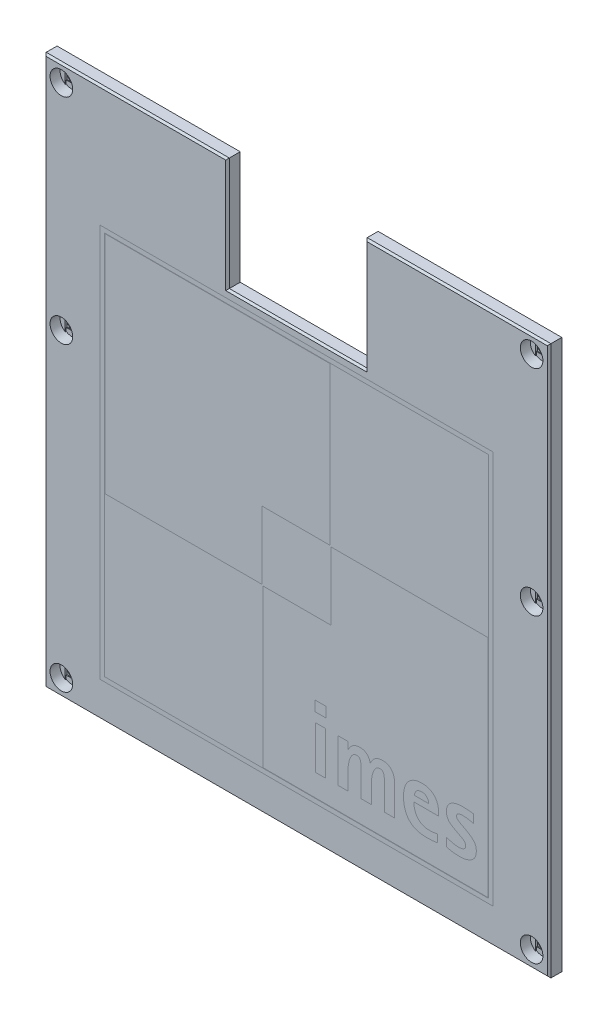
from build123d import *

# Parameters (mm, degrees)
SKETCH1_R             = 1.35
BOSS_EXTRUDE1_DEPTH   = 2.8
SKETCH3_R             = 2.5
CUT_EXTRUDE1_DEPTH    = 2.2
SKETCH4_W             = 91.5
SKETCH4_H             = 85.5
CUT_EXTRUDE2_DEPTH    = 1.5
CUT_EXTRUDE3_DEPTH    = 0.2
SKETCH6_W             = 2.7
SKETCH6_H             = 2.7
CUT_EXTRUDE4_DEPTH    = 0.2
CHAMFER1_SIZE         = 0.4
CUT_EXTRUDE5_DEPTH    = 1
BOSS_EXTRUDE2_DEPTH   = 1
BOSS_EXTRUDE2_2_DEPTH = 1
SKETCH10_W            = 87
SKETCH10_H            = 87
SKETCH10_W_2          = 85
SKETCH10_H_2          = 85
CUT_EXTRUDE6_DEPTH    = 1
SKETCH10_2_W          = 87
SKETCH10_2_H          = 87
SKETCH10_2_W_2        = 85
SKETCH10_2_H_2        = 85
BOSS_EXTRUDE3_DEPTH   = 1
SKETCH11_W            = 2.420833333
SKETCH11_H            = 2.24
SKETCH11_W_2          = 2.237083334
SKETCH11_H_2          = 9.52
CUT_EXTRUDE7_DEPTH    = 1
SKETCH11_2_W          = 2.420833333
SKETCH11_2_H          = 2.24
BOSS_EXTRUDE4_DEPTH   = 1
SKETCH11_2_W_2        = 2.237083334
SKETCH11_2_H_2        = 9.52
BOSS_EXTRUDE4_2_DEPTH = 1
BOSS_EXTRUDE4_3_DEPTH = 1
BOSS_EXTRUDE4_4_DEPTH = 1
BOSS_EXTRUDE4_5_DEPTH = 1


with BuildPart() as part:
    # Sketch1 → Boss-Extrude1 (new body)
    with BuildSketch(Plane.XY):
        Polygon((-15.25, 53.75), (-15.25, 28.75), (15.25, 28.75), (15.25, 53.75), (55.875, 53.75), (55.875, -67.75), (-55.75, -67.75), (-55.75, 53.75), align=None)
        with Locations((-52, 50)):
            Circle(SKETCH1_R, mode=Mode.SUBTRACT)
        with Locations((-52, 2.6)):
            Circle(SKETCH1_R, mode=Mode.SUBTRACT)
        with Locations((-52, -64)):
            Circle(SKETCH1_R, mode=Mode.SUBTRACT)
        with Locations((52, 50)):
            Circle(SKETCH1_R, mode=Mode.SUBTRACT)
        with Locations((52, 2.6)):
            Circle(SKETCH1_R, mode=Mode.SUBTRACT)
        with Locations((52, -64)):
            Circle(SKETCH1_R, mode=Mode.SUBTRACT)
    extrude(amount=BOSS_EXTRUDE1_DEPTH)

    # Sketch3 → Cut-Extrude1 (cut)
    with BuildSketch(Plane.XY.offset(2.8)):
        with Locations((-52, 50)):
            Circle(SKETCH3_R)
        with Locations((-52, 2.6)):
            Circle(SKETCH3_R)
        with Locations((-52, -64)):
            Circle(SKETCH3_R)
        with Locations((52, -64)):
            Circle(SKETCH3_R)
        with Locations((52, 2.6)):
            Circle(SKETCH3_R)
        with Locations((52, 50)):
            Circle(SKETCH3_R)
    extrude(amount=-CUT_EXTRUDE1_DEPTH, mode=Mode.SUBTRACT)

    # Sketch4 → Cut-Extrude2 (cut)
    with BuildSketch(Plane(origin=(0, 0, 0), x_dir=(-1, 0, 0), z_dir=(0, 0, -1))):
        with Locations((0, -15)):
            Rectangle(SKETCH4_W, SKETCH4_H)
    extrude(amount=-CUT_EXTRUDE2_DEPTH, mode=Mode.SUBTRACT)

    # Sketch5 → Cut-Extrude3 (cut)
    with BuildSketch(Plane.XY.offset(0.6)):
        with BuildLine():
            Line((-53.35, 47.895837459), (-53.35, 52.104162541))
            ThreePointArc((-53.35, 52.104162541), (-52, 52.5), (-50.65, 52.104162541))
            Line((-50.65, 52.104162541), (-50.65, 47.895837459))
            ThreePointArc((-50.65, 47.895837459), (-52, 47.5), (-53.35, 47.895837459))
        make_face()
        with BuildLine():
            Line((-53.35, 0.495837459), (-53.35, 4.704162541))
            ThreePointArc((-53.35, 4.704162541), (-52, 5.1), (-50.65, 4.704162541))
            Line((-50.65, 4.704162541), (-50.65, 0.495837459))
            ThreePointArc((-50.65, 0.495837459), (-52, 0.1), (-53.35, 0.495837459))
        make_face()
        with BuildLine():
            Line((-53.35, -66.104162541), (-53.35, -61.895837459))
            ThreePointArc((-53.35, -61.895837459), (-52, -61.5), (-50.65, -61.895837459))
            Line((-50.65, -61.895837459), (-50.65, -66.104162541))
            ThreePointArc((-50.65, -66.104162541), (-52, -66.5), (-53.35, -66.104162541))
        make_face()
    cut_extrude3 = extrude(amount=-CUT_EXTRUDE3_DEPTH, mode=Mode.SUBTRACT)

    # Sketch6 → Cut-Extrude4 (cut)
    with BuildSketch(Plane.XY.offset(0.4)):
        with Locations((-52, -64)):
            Rectangle(SKETCH6_W, SKETCH6_H)
        with Locations((-52, 2.6)):
            Rectangle(SKETCH6_W, SKETCH6_H)
        with Locations((-52, 50)):
            Rectangle(SKETCH6_W, SKETCH6_H)
    cut_extrude4 = extrude(amount=-CUT_EXTRUDE4_DEPTH, mode=Mode.SUBTRACT)

    # Mirror1: Cut-Extrude3, Cut-Extrude4 across plane
    add(cut_extrude3.mirror(Plane(origin=(0, 0, 0), x_dir=(0, 0, 1), z_dir=(1, 0, 0))), mode=Mode.SUBTRACT)
    add(cut_extrude4.mirror(Plane(origin=(0, 0, 0), x_dir=(0, 0, 1), z_dir=(1, 0, 0))), mode=Mode.SUBTRACT)

    # Chamfer1
    chamfer1_edges = [part.edges().sort_by_distance(p)[0] for p in [
        (55.875, -7, 2.8),
        (35.5625, 53.75, 2.8),
        (15.25, 41.25, 2.8),
        (0, 28.75, 2.8),
        (-15.25, 41.25, 2.8),
        (-35.5, 53.75, 2.8),
        (-55.75, -7, 2.8),
        (0.0625, -67.75, 2.8),
    ]]
    chamfer(chamfer1_edges, length=CHAMFER1_SIZE)

    # Sketch8 → Cut-Extrude5 (cut)
    with BuildSketch(Plane.XY.offset(2.8)):
        Polygon((7.4, -8.9), (7.4, 25.9), (-42.4, 25.9), (-42.4, -23.9), (-7.6, -23.9), (-7.6, -8.9), align=None)
        Polygon((7.6, -9.1), (42.4, -9.1), (42.4, -58.9), (-7.4, -58.9), (-7.4, -24.1), (7.6, -24.1), align=None)
    extrude(amount=-CUT_EXTRUDE5_DEPTH, mode=Mode.SUBTRACT)

    # Sketch10 → Cut-Extrude6 (cut)
    with BuildSketch(Plane.XY.offset(2.8)):
        with Locations((0, -16.5)):
            Rectangle(SKETCH10_W, SKETCH10_H)
        with Locations((0, -16.5)):
            Rectangle(SKETCH10_W_2, SKETCH10_H_2, mode=Mode.SUBTRACT)
    extrude(amount=-CUT_EXTRUDE6_DEPTH, mode=Mode.SUBTRACT)


with BuildPart() as body_2:
    # Sketch9 → Boss-Extrude2 (new body)
    with BuildSketch(Plane.XY.offset(1.8)):
        Polygon((42.4, -58.9), (42.4, -9.1), (7.6, -9.1), (7.6, -24.1), (-7.4, -24.1), (-7.4, -58.9), align=None)
    extrude(amount=BOSS_EXTRUDE2_DEPTH)

    # Sketch11 → Cut-Extrude7 (cut)
    with BuildSketch(Plane.XY.offset(2.8)):
        with Locations((5.301989939, -41.306666667)):
            Rectangle(SKETCH11_W, SKETCH11_H)
        with Locations((5.312198272, -49.24)):
            Rectangle(SKETCH11_W_2, SKETCH11_H_2)
        with BuildLine():
            Line((16.551573272, -54), (14.314489939, -54))
            Line((14.314489939, -54), (14.314489939, -48.668333333))
            add(Edge.make_bspline(
                [(14.314489939, -48.668333333), (14.313686685, -48.482571253), (14.312175479, -48.133086674), (14.278360319, -47.640712175), (14.232210349, -47.211572426), (14.172597166, -46.893633433), (14.107175652, -46.674232022), (14.042196618, -46.535243015), (13.957841011, -46.418719337), (13.856161095, -46.322230666), (13.736942045, -46.248548263), (13.601692447, -46.195614954), (13.448414032, -46.167272457), (13.34140672, -46.162513003), (13.284906605, -46.16)],
                knots=[0, 0, 0, 0, 0.000557152, 0.001048201, 0.001479809, 0.001851612, 0.002016733, 0.002165454, 0.002309556, 0.002445737, 0.002583316, 0.002727389, 0.002878971, 0.00304854, 0.00304854, 0.00304854, 0.00304854], degree=3))
            add(Edge.make_bspline(
                [(13.284906605, -46.16), (13.23232302, -46.162736834), (13.129269761, -46.168100479), (12.976620173, -46.195969001), (12.834650775, -46.25367671), (12.65031574, -46.353254313), (12.435900889, -46.529460995), (12.213950311, -46.801404357), (12.017705386, -47.124509235), (11.844159352, -47.488037139), (11.697897987, -47.886450243), (11.628537057, -48.166876883), (11.593239939, -48.309583333)],
                knots=[0, 0, 0, 0, 0.000157932, 0.000309514, 0.000462799, 0.000615499, 0.000937088, 0.001287003, 0.00166419, 0.002068598, 0.002493961, 0.002934726, 0.002934726, 0.002934726, 0.002934726], degree=3))
            add(Edge.make_bspline(
                [(11.593239939, -48.309583333), (11.562337157, -48.458025184), (11.499815905, -48.758346705), (11.437775373, -49.216251476), (11.39825174, -49.677767314), (11.394066278, -49.985615063), (11.391989939, -50.138333333)],
                knots=[0, 0, 0, 0, 0.000454748, 0.000920027, 0.001385324, 0.001843389, 0.001843389, 0.001843389, 0.001843389], degree=3))
            Line((11.391989939, -50.138333333), (11.391989939, -54))
            Line((11.391989939, -54), (9.151989939, -54))
            Line((9.151989939, -54), (9.151989939, -44.48))
            Line((9.151989939, -44.48), (11.371573272, -44.48))
            Line((11.371573272, -44.48), (11.371573272, -46.09875))
            Line((11.371573272, -46.09875), (11.409489939, -46.09875))
            add(Edge.make_bspline(
                [(11.409489939, -46.09875), (11.473376644, -45.963842947), (11.59767667, -45.70136345), (11.834161815, -45.343504102), (12.106671485, -45.033324948), (12.412237587, -44.764956333), (12.76140059, -44.551444881), (13.154373097, -44.399999465), (13.589804927, -44.3075479), (13.894010556, -44.298192012), (14.051989939, -44.293333333)],
                knots=[0, 0, 0, 0, 0.000447402, 0.000870479, 0.001281771, 0.001682916, 0.002086092, 0.002502603, 0.002940783, 0.003414183, 0.003414183, 0.003414183, 0.003414183], degree=3))
            add(Edge.make_bspline(
                [(14.051989939, -44.293333333), (14.196386101, -44.29832864), (14.473501185, -44.307915285), (14.866870226, -44.397474346), (15.21860961, -44.540852097), (15.527812089, -44.744235726), (15.788505717, -45.01175304), (16.006545498, -45.334125761), (16.175536509, -45.716406069), (16.250138065, -45.994462985), (16.289073272, -46.139583333)],
                knots=[0, 0, 0, 0, 0.000432651, 0.000830314, 0.001202974, 0.001566997, 0.001932047, 0.002316306, 0.002728836, 0.003179176, 0.003179176, 0.003179176, 0.003179176], degree=3))
            Line((16.289073272, -46.139583333), (16.329906605, -46.139583333))
            add(Edge.make_bspline(
                [(16.329906605, -46.139583333), (16.404348942, -45.987351559), (16.547523057, -45.694565886), (16.8236893, -45.311447986), (17.121737493, -44.984613501), (17.459823406, -44.729169162), (17.823197859, -44.532075393), (18.212208596, -44.394825734), (18.623245144, -44.30604211), (18.906798996, -44.297620689), (19.051156605, -44.293333333)],
                knots=[0, 0, 0, 0, 0.000507508, 0.000976085, 0.00141149, 0.001829755, 0.002240839, 0.002646769, 0.003063771, 0.003496235, 0.003496235, 0.003496235, 0.003496235], degree=3))
            add(Edge.make_bspline(
                [(19.051156605, -44.293333333), (19.162128041, -44.296011447), (19.377211358, -44.301202132), (19.688626773, -44.344652447), (19.976385472, -44.420507531), (20.241337234, -44.526459651), (20.482962243, -44.658263208), (20.705873265, -44.810645716), (20.903417048, -44.990290645), (21.082778761, -45.188600097), (21.237433908, -45.408549884), (21.369170289, -45.647567577), (21.481323721, -45.903631134), (21.563276586, -46.180808014), (21.631177774, -46.470870114), (21.676327358, -46.776265483), (21.707264981, -47.094636368), (21.709841789, -47.312004545), (21.711156605, -47.422916667)],
                knots=[0, 0, 0, 0, 0.00033282, 0.000645066, 0.000940788, 0.001223509, 0.001498884, 0.001765068, 0.002031509, 0.002297949, 0.002565806, 0.002836067, 0.003115641, 0.003402559, 0.00370184, 0.004008743, 0.004327994, 0.004660609, 0.004660609, 0.004660609, 0.004660609], degree=3))
            Line((21.711156605, -47.422916667), (21.711156605, -54))
            Line((21.711156605, -54), (19.474073272, -54))
            Line((19.474073272, -54), (19.474073272, -48.528333333))
            add(Edge.make_bspline(
                [(19.474073272, -48.528333333), (19.473221838, -48.352300679), (19.471620776, -48.021283271), (19.438440361, -47.554996781), (19.390322126, -47.149732416), (19.336041322, -46.849239036), (19.269011046, -46.642620111), (19.202165981, -46.512626337), (19.11640835, -46.403519726), (19.013809355, -46.311632834), (18.890844571, -46.243276631), (18.751058454, -46.192975161), (18.594449059, -46.163785788), (18.484477246, -46.161299629), (18.426989939, -46.16)],
                knots=[0, 0, 0, 0, 0.000527989, 0.000992848, 0.001401285, 0.001752498, 0.00190653, 0.002051339, 0.002188454, 0.002320704, 0.002461794, 0.002607569, 0.00276488, 0.002937185, 0.002937185, 0.002937185, 0.002937185], degree=3))
            add(Edge.make_bspline(
                [(18.426989939, -46.16), (18.331576773, -46.166361664), (18.142443407, -46.178972115), (17.874558895, -46.293299659), (17.628727852, -46.470616752), (17.415067159, -46.718757608), (17.227199685, -47.014314201), (17.052738095, -47.341616073), (16.908240641, -47.704310355), (16.832471045, -47.959901718), (16.793656605, -48.090833333)],
                knots=[0, 0, 0, 0, 0.000285073, 0.000565089, 0.00085973, 0.001188175, 0.001540078, 0.001909299, 0.00229926, 0.002708842, 0.002708842, 0.002708842, 0.002708842], degree=3))
            add(Edge.make_bspline(
                [(16.793656605, -48.090833333), (16.755177885, -48.253678629), (16.67668304, -48.585875653), (16.60531819, -49.097325017), (16.560133047, -49.617366396), (16.554418238, -49.965182409), (16.551573272, -50.138333333)],
                knots=[0, 0, 0, 0, 0.000501743, 0.001023533, 0.001547446, 0.002066818, 0.002066818, 0.002066818, 0.002066818], degree=3))
            Line((16.551573272, -50.138333333), (16.551573272, -54))
        make_face()
        with BuildLine():
            add(Edge.make_bspline(
                [(31.146573272, -54), (30.948633988, -54.034140742), (30.544754004, -54.103802319), (29.925184631, -54.152030212), (29.296764308, -54.182125246), (28.876476435, -54.185158027), (28.667406605, -54.186666667)],
                knots=[0, 0, 0, 0, 0.000602276, 0.001228898, 0.001862486, 0.00248963, 0.00248963, 0.00248963, 0.00248963], degree=3))
            add(Edge.make_bspline(
                [(28.667406605, -54.186666667), (28.456245849, -54.182438475), (28.048238171, -54.174268705), (27.458086548, -54.104586272), (26.914315853, -53.985052647), (26.413389292, -53.823111993), (25.958466237, -53.61096192), (25.545424205, -53.35983915), (25.172490736, -53.06978598), (24.848075621, -52.733605079), (24.56359642, -52.361388441), (24.321808959, -51.952971154), (24.115558498, -51.511786768), (23.950937542, -51.035321785), (23.823165687, -50.527705633), (23.734384439, -49.991101409), (23.676835479, -49.426953028), (23.671148832, -49.040841259), (23.668239939, -48.843333333)],
                knots=[0, 0, 0, 0, 0.000633347, 0.001223761, 0.001779285, 0.002301327, 0.002799804, 0.003281513, 0.003748881, 0.004212962, 0.004679063, 0.005151257, 0.005634051, 0.006137698, 0.006661172, 0.007202526, 0.007768164, 0.008360506, 0.008360506, 0.008360506, 0.008360506], degree=3))
            add(Edge.make_bspline(
                [(23.668239939, -48.843333333), (23.670679906, -48.683765408), (23.675481498, -48.369752948), (23.724138608, -47.907889675), (23.799476888, -47.463493977), (23.902825551, -47.037454676), (24.040180862, -46.634305104), (24.20702458, -46.255897891), (24.41514747, -45.910733069), (24.646761925, -45.589161825), (24.918900043, -45.302050501), (25.222341231, -45.04312192), (25.564128522, -44.822262536), (25.93686423, -44.629930644), (26.346875594, -44.477947118), (26.793581426, -44.372469228), (27.274912743, -44.302241295), (27.608390334, -44.296368527), (27.780739939, -44.293333333)],
                knots=[0, 0, 0, 0, 0.000478556, 0.000941746, 0.001391518, 0.001830106, 0.002255309, 0.00266784, 0.003068008, 0.003462363, 0.003854413, 0.004251765, 0.004656247, 0.00507236, 0.005507951, 0.00596423, 0.006447244, 0.006963898, 0.006963898, 0.006963898, 0.006963898], degree=3))
            add(Edge.make_bspline(
                [(27.780739939, -44.293333333), (27.927749627, -44.296168181), (28.213164749, -44.301671958), (28.627108854, -44.359295882), (29.013618747, -44.44785181), (29.371982236, -44.574644967), (29.702759219, -44.731671309), (30.004706565, -44.920287518), (30.280746502, -45.132921366), (30.527025179, -45.374775719), (30.746906172, -45.639519393), (30.934207828, -45.932557372), (31.095285588, -46.246455255), (31.222178659, -46.58497307), (31.325446112, -46.941604739), (31.396722231, -47.317584093), (31.442140258, -47.711524243), (31.447279013, -47.979870318), (31.449906605, -48.117083333)],
                knots=[0, 0, 0, 0, 0.000440764, 0.000855731, 0.001251206, 0.001628494, 0.001993777, 0.002347464, 0.002694597, 0.003036979, 0.003380923, 0.003724756, 0.004078251, 0.00443738, 0.004807567, 0.005190817, 0.005584092, 0.0059956, 0.0059956, 0.0059956, 0.0059956], degree=3))
            Line((31.449906605, -48.117083333), (31.449906605, -48.773333333))
            Line((31.449906605, -48.773333333), (25.986989939, -48.773333333))
            Line((25.986989939, -48.773333333), (25.986989939, -49.00375))
            add(Edge.make_bspline(
                [(25.986989939, -49.00375), (25.990016312, -49.120522993), (25.996011873, -49.351862431), (26.037122844, -49.694604786), (26.10804176, -50.027889506), (26.203223457, -50.351297159), (26.32573212, -50.659481766), (26.470807623, -50.950931588), (26.645687078, -51.218813195), (26.836439446, -51.472399643), (27.057367822, -51.700666376), (27.302957561, -51.906237625), (27.575802393, -52.083962617), (27.87159575, -52.235978332), (28.190130956, -52.361024318), (28.533023193, -52.441995963), (28.895035571, -52.497756307), (29.14356878, -52.503644093), (29.271156605, -52.506666667)],
                knots=[0, 0, 0, 0, 0.000350304, 0.000693988, 0.001033777, 0.001371531, 0.001704082, 0.002027569, 0.002346341, 0.002662527, 0.002978134, 0.003297053, 0.003621446, 0.00395278, 0.004293481, 0.004645057, 0.005007628, 0.005390112, 0.005390112, 0.005390112, 0.005390112], degree=3))
            add(Edge.make_bspline(
                [(29.271156605, -52.506666667), (29.420928332, -52.50410257), (29.723712122, -52.498918903), (30.185228493, -52.466193349), (30.661376762, -52.408280475), (30.982529838, -52.349847355), (31.146573272, -52.32)],
                knots=[0, 0, 0, 0, 0.000449318, 0.000908357, 0.001387339, 0.001887461, 0.001887461, 0.001887461, 0.001887461], degree=3))
            Line((31.146573272, -52.32), (31.146573272, -54))
        make_face()
        with BuildLine():
            add(Edge.make_bspline(
                [(29.212823272, -47.466666667), (29.208035518, -47.360182944), (29.198809364, -47.154985419), (29.120869207, -46.863625482), (28.99437493, -46.602983764), (28.814030536, -46.381041645), (28.593899503, -46.197837668), (28.334107621, -46.062851436), (28.036648478, -45.987984351), (27.827816191, -45.978337423), (27.719489939, -45.973333333)],
                knots=[0, 0, 0, 0, 0.000318999, 0.00061472, 0.000897772, 0.001182009, 0.001465826, 0.001751511, 0.002052874, 0.002377687, 0.002377687, 0.002377687, 0.002377687], degree=3))
            add(Edge.make_bspline(
                [(27.719489939, -45.973333333), (27.599316962, -45.977315453), (27.369238364, -45.984939468), (27.046970022, -46.071496707), (26.765767901, -46.210086181), (26.53506651, -46.406413396), (26.34953053, -46.637692001), (26.204186349, -46.892808506), (26.099293874, -47.170474379), (26.065469401, -47.366708967), (26.048239939, -47.466666667)],
                knots=[0, 0, 0, 0, 0.000359709, 0.000688685, 0.000992607, 0.001292854, 0.001589394, 0.001878085, 0.00217064, 0.00247438, 0.00247438, 0.00247438, 0.00247438], degree=3))
            Line((26.048239939, -47.466666667), (29.212823272, -47.466666667))
        make_face(mode=Mode.SUBTRACT)
        with BuildLine():
            add(Edge.make_bspline(
                [(33.161989939, -51.9), (33.368068782, -51.978728517), (33.797278016, -52.142699772), (34.357450386, -52.302658945), (34.824411999, -52.407471893), (35.173287842, -52.461996702), (35.511994701, -52.4998336), (35.735363956, -52.504412556), (35.845323272, -52.506666667)],
                knots=[0, 0, 0, 0, 0.000661595, 0.001377932, 0.001745224, 0.002096703, 0.002436842, 0.002766632, 0.002766632, 0.002766632, 0.002766632], degree=3))
            add(Edge.make_bspline(
                [(35.845323272, -52.506666667), (35.943641536, -52.503675986), (36.136283813, -52.497816123), (36.417390575, -52.457531823), (36.683190912, -52.385628124), (36.931171174, -52.291788695), (37.152531344, -52.159055981), (37.310605718, -51.961855601), (37.404833585, -51.716274695), (37.413040722, -51.537294139), (37.417406605, -51.442083333)],
                knots=[0, 0, 0, 0, 0.000294944, 0.000577906, 0.000849579, 0.001119304, 0.001372533, 0.001613048, 0.001863287, 0.002147703, 0.002147703, 0.002147703, 0.002147703], degree=3))
            add(Edge.make_bspline(
                [(37.417406605, -51.442083333), (37.411718146, -51.360675708), (37.400494686, -51.200056601), (37.313093358, -50.971872004), (37.162378417, -50.773294905), (36.882936233, -50.543820043), (36.464548959, -50.284166829), (36.109788151, -50.090806274), (35.924073272, -49.989583333)],
                knots=[0, 0, 0, 0, 0.000243834, 0.00048109, 0.000720843, 0.000983424, 0.001561042, 0.002195616, 0.002195616, 0.002195616, 0.002195616], degree=3))
            Line((35.924073272, -49.989583333), (35.078239939, -49.557916667))
            add(Edge.make_bspline(
                [(35.078239939, -49.557916667), (34.953522446, -49.490406096), (34.70843798, -49.357739926), (34.350741778, -49.152249179), (34.025905871, -48.9120705), (33.737948283, -48.631074531), (33.501999766, -48.299054353), (33.339947764, -47.991521987), (33.247088218, -47.717883573), (33.199120342, -47.490720997), (33.164819096, -47.245064654), (33.162955372, -47.074020044), (33.161989939, -46.985416667)],
                knots=[0, 0, 0, 0, 0.000425514, 0.000836184, 0.001236352, 0.0016344, 0.002037544, 0.002453657, 0.002672252, 0.002902243, 0.003149335, 0.003414896, 0.003414896, 0.003414896, 0.003414896], degree=3))
            add(Edge.make_bspline(
                [(33.161989939, -46.985416667), (33.164297721, -46.875362497), (33.168772536, -46.661966265), (33.217429528, -46.35310362), (33.29209579, -46.066115963), (33.397450718, -45.799728048), (33.536190361, -45.556351156), (33.702818101, -45.33300419), (33.901243238, -45.132075848), (34.130201319, -44.955291936), (34.383383784, -44.797856113), (34.660446513, -44.664984685), (34.955535923, -44.546006226), (35.274649144, -44.454682721), (35.613767934, -44.381904617), (35.974161588, -44.328813656), (36.356282182, -44.301314232), (36.618201633, -44.296037222), (36.752406605, -44.293333333)],
                knots=[0, 0, 0, 0, 0.000329906, 0.000639691, 0.000935413, 0.001218134, 0.001496336, 0.001773419, 0.00205185, 0.002340659, 0.002639315, 0.002944549, 0.003261394, 0.003592727, 0.003938829, 0.0043014, 0.004684595, 0.005087264, 0.005087264, 0.005087264, 0.005087264], degree=3))
            add(Edge.make_bspline(
                [(36.752406605, -44.293333333), (36.950807244, -44.2953891), (37.356707072, -44.29959491), (37.968387386, -44.340705803), (38.576895336, -44.39449896), (38.97608376, -44.45201399), (39.170323272, -44.48)],
                knots=[0, 0, 0, 0, 0.000595114, 0.00121752, 0.001838599, 0.002427224, 0.002427224, 0.002427224, 0.002427224], degree=3))
            Line((39.170323272, -44.48), (39.170323272, -46.346666667))
            add(Edge.make_bspline(
                [(39.170323272, -46.346666667), (38.988108904, -46.295699072), (38.611912226, -46.190472247), (38.028162579, -46.076138578), (37.430673341, -45.987872713), (37.028830455, -45.978127287), (36.831156605, -45.973333333)],
                knots=[0, 0, 0, 0, 0.000567395, 0.001171434, 0.001783572, 0.002376237, 0.002376237, 0.002376237, 0.002376237], degree=3))
            add(Edge.make_bspline(
                [(36.831156605, -45.973333333), (36.728926352, -45.975019354), (36.534371572, -45.978228027), (36.257864218, -46.017124715), (36.011637315, -46.076862262), (35.797688152, -46.159212935), (35.617902783, -46.267815049), (35.491933882, -46.41702891), (35.408503179, -46.594484771), (35.402308183, -46.724845005), (35.399073272, -46.792916667)],
                knots=[0, 0, 0, 0, 0.000306472, 0.000583248, 0.000835789, 0.001064891, 0.001269578, 0.00145781, 0.001643196, 0.001845794, 0.001845794, 0.001845794, 0.001845794], degree=3))
            add(Edge.make_bspline(
                [(35.399073272, -46.792916667), (35.405469285, -46.865397073), (35.418289297, -47.01067503), (35.536515376, -47.207500082), (35.705028757, -47.375394503), (35.907900312, -47.541014425), (36.153722896, -47.694310227), (36.435226491, -47.842321721), (36.741341887, -47.991483787), (36.948094054, -48.100021032), (37.052823272, -48.155)],
                knots=[0, 0, 0, 0, 0.000215774, 0.000432493, 0.000669749, 0.000928938, 0.001216167, 0.001537173, 0.001882832, 0.002237659, 0.002237659, 0.002237659, 0.002237659], degree=3))
            Line((37.052823272, -48.155), (37.919073272, -48.639166667))
            add(Edge.make_bspline(
                [(37.919073272, -48.639166667), (38.048404639, -48.718272754), (38.301833538, -48.873283631), (38.657064143, -49.12775227), (38.969541134, -49.409317633), (39.254010776, -49.700899499), (39.494128853, -50.027859733), (39.656394254, -50.407688982), (39.758497008, -50.830046536), (39.768753596, -51.127427307), (39.774073272, -51.281666667)],
                knots=[0, 0, 0, 0, 0.000454785, 0.000891165, 0.001308504, 0.001714926, 0.0021123, 0.002517129, 0.002945839, 0.003407788, 0.003407788, 0.003407788, 0.003407788], degree=3))
            add(Edge.make_bspline(
                [(39.774073272, -51.281666667), (39.77038231, -51.400421566), (39.763212816, -51.631096499), (39.717274784, -51.965982495), (39.636251837, -52.277989946), (39.517769421, -52.564835898), (39.37209742, -52.83134625), (39.18995068, -53.071755881), (38.973183967, -53.286207089), (38.72891469, -53.478772192), (38.45472695, -53.643905915), (38.161158819, -53.789564745), (37.845647761, -53.912448264), (37.510398079, -54.014515976), (37.153393208, -54.092789442), (36.775246492, -54.147959264), (36.376695017, -54.17944131), (36.103989102, -54.184226286), (35.964906605, -54.186666667)],
                knots=[0, 0, 0, 0, 0.000356263, 0.000692022, 0.001011793, 0.001320519, 0.001620809, 0.001920644, 0.002221754, 0.002533332, 0.002851476, 0.003180181, 0.003515446, 0.003866053, 0.004230496, 0.004610805, 0.005011674, 0.005428921, 0.005428921, 0.005428921, 0.005428921], degree=3))
            add(Edge.make_bspline(
                [(35.964906605, -54.186666667), (35.736270613, -54.180700274), (35.26433815, -54.168384915), (34.551493911, -54.095718416), (33.840615896, -53.973493013), (33.384457616, -53.834468637), (33.161989939, -53.766666667)],
                knots=[0, 0, 0, 0, 0.000685919, 0.00141582, 0.002148095, 0.002845203, 0.002845203, 0.002845203, 0.002845203], degree=3))
            Line((33.161989939, -53.766666667), (33.161989939, -51.9))
        make_face()
    extrude(amount=-CUT_EXTRUDE7_DEPTH, mode=Mode.SUBTRACT)


with BuildPart() as body_3:
    # Sketch9 → Boss-Extrude2 2 (new body)
    with BuildSketch(Plane.XY.offset(1.8)):
        Polygon((-7.6, -8.9), (7.4, -8.9), (7.4, 25.9), (-42.4, 25.9), (-42.4, -23.9), (-7.6, -23.9), align=None)
    extrude(amount=BOSS_EXTRUDE2_2_DEPTH)


with BuildPart() as body_4:
    # Sketch10_2 → Boss-Extrude3 (new body)
    with BuildSketch(Plane.XY.offset(2.8)):
        with Locations((0, -16.5)):
            Rectangle(SKETCH10_2_W, SKETCH10_2_H)
        with Locations((0, -16.5)):
            Rectangle(SKETCH10_2_W_2, SKETCH10_2_H_2, mode=Mode.SUBTRACT)
    extrude(amount=-BOSS_EXTRUDE3_DEPTH)


with BuildPart() as body_5:
    # Sketch11_2 → Boss-Extrude4 (new body)
    with BuildSketch(Plane.XY.offset(2.8)):
        with Locations((5.301989939, -41.306666667)):
            Rectangle(SKETCH11_2_W, SKETCH11_2_H)
    extrude(amount=-BOSS_EXTRUDE4_DEPTH)


with BuildPart() as body_6:
    # Sketch11_2 → Boss-Extrude4 2 (new body)
    with BuildSketch(Plane.XY.offset(2.8)):
        with Locations((5.312198272, -49.24)):
            Rectangle(SKETCH11_2_W_2, SKETCH11_2_H_2)
    extrude(amount=-BOSS_EXTRUDE4_2_DEPTH)


with BuildPart() as body_7:
    # Sketch11_2 → Boss-Extrude4 3 (new body)
    with BuildSketch(Plane.XY.offset(2.8)):
        with BuildLine():
            Line((16.551573272, -54), (14.314489939, -54))
            Line((14.314489939, -54), (14.314489939, -48.668333333))
            add(Edge.make_bspline(
                [(14.314489939, -48.668333333), (14.313686685, -48.482571253), (14.312175479, -48.133086674), (14.278360319, -47.640712175), (14.232210349, -47.211572426), (14.172597166, -46.893633433), (14.107175652, -46.674232022), (14.042196618, -46.535243015), (13.957841011, -46.418719337), (13.856161095, -46.322230666), (13.736942045, -46.248548263), (13.601692447, -46.195614954), (13.448414032, -46.167272457), (13.34140672, -46.162513003), (13.284906605, -46.16)],
                knots=[0, 0, 0, 0, 0.000557152, 0.001048201, 0.001479809, 0.001851612, 0.002016733, 0.002165454, 0.002309556, 0.002445737, 0.002583316, 0.002727389, 0.002878971, 0.00304854, 0.00304854, 0.00304854, 0.00304854], degree=3))
            add(Edge.make_bspline(
                [(13.284906605, -46.16), (13.23232302, -46.162736834), (13.129269761, -46.168100479), (12.976620173, -46.195969001), (12.834650775, -46.25367671), (12.65031574, -46.353254313), (12.435900889, -46.529460995), (12.213950311, -46.801404357), (12.017705386, -47.124509235), (11.844159352, -47.488037139), (11.697897987, -47.886450243), (11.628537057, -48.166876883), (11.593239939, -48.309583333)],
                knots=[0, 0, 0, 0, 0.000157932, 0.000309514, 0.000462799, 0.000615499, 0.000937088, 0.001287003, 0.00166419, 0.002068598, 0.002493961, 0.002934726, 0.002934726, 0.002934726, 0.002934726], degree=3))
            add(Edge.make_bspline(
                [(11.593239939, -48.309583333), (11.562337157, -48.458025184), (11.499815905, -48.758346705), (11.437775373, -49.216251476), (11.39825174, -49.677767314), (11.394066278, -49.985615063), (11.391989939, -50.138333333)],
                knots=[0, 0, 0, 0, 0.000454748, 0.000920027, 0.001385324, 0.001843389, 0.001843389, 0.001843389, 0.001843389], degree=3))
            Line((11.391989939, -50.138333333), (11.391989939, -54))
            Line((11.391989939, -54), (9.151989939, -54))
            Line((9.151989939, -54), (9.151989939, -44.48))
            Line((9.151989939, -44.48), (11.371573272, -44.48))
            Line((11.371573272, -44.48), (11.371573272, -46.09875))
            Line((11.371573272, -46.09875), (11.409489939, -46.09875))
            add(Edge.make_bspline(
                [(11.409489939, -46.09875), (11.473376644, -45.963842947), (11.59767667, -45.70136345), (11.834161815, -45.343504102), (12.106671485, -45.033324948), (12.412237587, -44.764956333), (12.76140059, -44.551444881), (13.154373097, -44.399999465), (13.589804927, -44.3075479), (13.894010556, -44.298192012), (14.051989939, -44.293333333)],
                knots=[0, 0, 0, 0, 0.000447402, 0.000870479, 0.001281771, 0.001682916, 0.002086092, 0.002502603, 0.002940783, 0.003414183, 0.003414183, 0.003414183, 0.003414183], degree=3))
            add(Edge.make_bspline(
                [(14.051989939, -44.293333333), (14.196386101, -44.29832864), (14.473501185, -44.307915285), (14.866870226, -44.397474346), (15.21860961, -44.540852097), (15.527812089, -44.744235726), (15.788505717, -45.01175304), (16.006545498, -45.334125761), (16.175536509, -45.716406069), (16.250138065, -45.994462985), (16.289073272, -46.139583333)],
                knots=[0, 0, 0, 0, 0.000432651, 0.000830314, 0.001202974, 0.001566997, 0.001932047, 0.002316306, 0.002728836, 0.003179176, 0.003179176, 0.003179176, 0.003179176], degree=3))
            Line((16.289073272, -46.139583333), (16.329906605, -46.139583333))
            add(Edge.make_bspline(
                [(16.329906605, -46.139583333), (16.404348942, -45.987351559), (16.547523057, -45.694565886), (16.8236893, -45.311447986), (17.121737493, -44.984613501), (17.459823406, -44.729169162), (17.823197859, -44.532075393), (18.212208596, -44.394825734), (18.623245144, -44.30604211), (18.906798996, -44.297620689), (19.051156605, -44.293333333)],
                knots=[0, 0, 0, 0, 0.000507508, 0.000976085, 0.00141149, 0.001829755, 0.002240839, 0.002646769, 0.003063771, 0.003496235, 0.003496235, 0.003496235, 0.003496235], degree=3))
            add(Edge.make_bspline(
                [(19.051156605, -44.293333333), (19.162128041, -44.296011447), (19.377211358, -44.301202132), (19.688626773, -44.344652447), (19.976385472, -44.420507531), (20.241337234, -44.526459651), (20.482962243, -44.658263208), (20.705873265, -44.810645716), (20.903417048, -44.990290645), (21.082778761, -45.188600097), (21.237433908, -45.408549884), (21.369170289, -45.647567577), (21.481323721, -45.903631134), (21.563276586, -46.180808014), (21.631177774, -46.470870114), (21.676327358, -46.776265483), (21.707264981, -47.094636368), (21.709841789, -47.312004545), (21.711156605, -47.422916667)],
                knots=[0, 0, 0, 0, 0.00033282, 0.000645066, 0.000940788, 0.001223509, 0.001498884, 0.001765068, 0.002031509, 0.002297949, 0.002565806, 0.002836067, 0.003115641, 0.003402559, 0.00370184, 0.004008743, 0.004327994, 0.004660609, 0.004660609, 0.004660609, 0.004660609], degree=3))
            Line((21.711156605, -47.422916667), (21.711156605, -54))
            Line((21.711156605, -54), (19.474073272, -54))
            Line((19.474073272, -54), (19.474073272, -48.528333333))
            add(Edge.make_bspline(
                [(19.474073272, -48.528333333), (19.473221838, -48.352300679), (19.471620776, -48.021283271), (19.438440361, -47.554996781), (19.390322126, -47.149732416), (19.336041322, -46.849239036), (19.269011046, -46.642620111), (19.202165981, -46.512626337), (19.11640835, -46.403519726), (19.013809355, -46.311632834), (18.890844571, -46.243276631), (18.751058454, -46.192975161), (18.594449059, -46.163785788), (18.484477246, -46.161299629), (18.426989939, -46.16)],
                knots=[0, 0, 0, 0, 0.000527989, 0.000992848, 0.001401285, 0.001752498, 0.00190653, 0.002051339, 0.002188454, 0.002320704, 0.002461794, 0.002607569, 0.00276488, 0.002937185, 0.002937185, 0.002937185, 0.002937185], degree=3))
            add(Edge.make_bspline(
                [(18.426989939, -46.16), (18.331576773, -46.166361664), (18.142443407, -46.178972115), (17.874558895, -46.293299659), (17.628727852, -46.470616752), (17.415067159, -46.718757608), (17.227199685, -47.014314201), (17.052738095, -47.341616073), (16.908240641, -47.704310355), (16.832471045, -47.959901718), (16.793656605, -48.090833333)],
                knots=[0, 0, 0, 0, 0.000285073, 0.000565089, 0.00085973, 0.001188175, 0.001540078, 0.001909299, 0.00229926, 0.002708842, 0.002708842, 0.002708842, 0.002708842], degree=3))
            add(Edge.make_bspline(
                [(16.793656605, -48.090833333), (16.755177885, -48.253678629), (16.67668304, -48.585875653), (16.60531819, -49.097325017), (16.560133047, -49.617366396), (16.554418238, -49.965182409), (16.551573272, -50.138333333)],
                knots=[0, 0, 0, 0, 0.000501743, 0.001023533, 0.001547446, 0.002066818, 0.002066818, 0.002066818, 0.002066818], degree=3))
            Line((16.551573272, -50.138333333), (16.551573272, -54))
        make_face()
    extrude(amount=-BOSS_EXTRUDE4_3_DEPTH)


with BuildPart() as body_8:
    # Sketch11_2 → Boss-Extrude4 4 (new body)
    with BuildSketch(Plane.XY.offset(2.8)):
        with BuildLine():
            add(Edge.make_bspline(
                [(31.146573272, -54), (30.948633988, -54.034140742), (30.544754004, -54.103802319), (29.925184631, -54.152030212), (29.296764308, -54.182125246), (28.876476435, -54.185158027), (28.667406605, -54.186666667)],
                knots=[0, 0, 0, 0, 0.000602276, 0.001228898, 0.001862486, 0.00248963, 0.00248963, 0.00248963, 0.00248963], degree=3))
            add(Edge.make_bspline(
                [(28.667406605, -54.186666667), (28.456245849, -54.182438475), (28.048238171, -54.174268705), (27.458086548, -54.104586272), (26.914315853, -53.985052647), (26.413389292, -53.823111993), (25.958466237, -53.61096192), (25.545424205, -53.35983915), (25.172490736, -53.06978598), (24.848075621, -52.733605079), (24.56359642, -52.361388441), (24.321808959, -51.952971154), (24.115558498, -51.511786768), (23.950937542, -51.035321785), (23.823165687, -50.527705633), (23.734384439, -49.991101409), (23.676835479, -49.426953028), (23.671148832, -49.040841259), (23.668239939, -48.843333333)],
                knots=[0, 0, 0, 0, 0.000633347, 0.001223761, 0.001779285, 0.002301327, 0.002799804, 0.003281513, 0.003748881, 0.004212962, 0.004679063, 0.005151257, 0.005634051, 0.006137698, 0.006661172, 0.007202526, 0.007768164, 0.008360506, 0.008360506, 0.008360506, 0.008360506], degree=3))
            add(Edge.make_bspline(
                [(23.668239939, -48.843333333), (23.670679906, -48.683765408), (23.675481498, -48.369752948), (23.724138608, -47.907889675), (23.799476888, -47.463493977), (23.902825551, -47.037454676), (24.040180862, -46.634305104), (24.20702458, -46.255897891), (24.41514747, -45.910733069), (24.646761925, -45.589161825), (24.918900043, -45.302050501), (25.222341231, -45.04312192), (25.564128522, -44.822262536), (25.93686423, -44.629930644), (26.346875594, -44.477947118), (26.793581426, -44.372469228), (27.274912743, -44.302241295), (27.608390334, -44.296368527), (27.780739939, -44.293333333)],
                knots=[0, 0, 0, 0, 0.000478556, 0.000941746, 0.001391518, 0.001830106, 0.002255309, 0.00266784, 0.003068008, 0.003462363, 0.003854413, 0.004251765, 0.004656247, 0.00507236, 0.005507951, 0.00596423, 0.006447244, 0.006963898, 0.006963898, 0.006963898, 0.006963898], degree=3))
            add(Edge.make_bspline(
                [(27.780739939, -44.293333333), (27.927749627, -44.296168181), (28.213164749, -44.301671958), (28.627108854, -44.359295882), (29.013618747, -44.44785181), (29.371982236, -44.574644967), (29.702759219, -44.731671309), (30.004706565, -44.920287518), (30.280746502, -45.132921366), (30.527025179, -45.374775719), (30.746906172, -45.639519393), (30.934207828, -45.932557372), (31.095285588, -46.246455255), (31.222178659, -46.58497307), (31.325446112, -46.941604739), (31.396722231, -47.317584093), (31.442140258, -47.711524243), (31.447279013, -47.979870318), (31.449906605, -48.117083333)],
                knots=[0, 0, 0, 0, 0.000440764, 0.000855731, 0.001251206, 0.001628494, 0.001993777, 0.002347464, 0.002694597, 0.003036979, 0.003380923, 0.003724756, 0.004078251, 0.00443738, 0.004807567, 0.005190817, 0.005584092, 0.0059956, 0.0059956, 0.0059956, 0.0059956], degree=3))
            Line((31.449906605, -48.117083333), (31.449906605, -48.773333333))
            Line((31.449906605, -48.773333333), (25.986989939, -48.773333333))
            Line((25.986989939, -48.773333333), (25.986989939, -49.00375))
            add(Edge.make_bspline(
                [(25.986989939, -49.00375), (25.990016312, -49.120522993), (25.996011873, -49.351862431), (26.037122844, -49.694604786), (26.10804176, -50.027889506), (26.203223457, -50.351297159), (26.32573212, -50.659481766), (26.470807623, -50.950931588), (26.645687078, -51.218813195), (26.836439446, -51.472399643), (27.057367822, -51.700666376), (27.302957561, -51.906237625), (27.575802393, -52.083962617), (27.87159575, -52.235978332), (28.190130956, -52.361024318), (28.533023193, -52.441995963), (28.895035571, -52.497756307), (29.14356878, -52.503644093), (29.271156605, -52.506666667)],
                knots=[0, 0, 0, 0, 0.000350304, 0.000693988, 0.001033777, 0.001371531, 0.001704082, 0.002027569, 0.002346341, 0.002662527, 0.002978134, 0.003297053, 0.003621446, 0.00395278, 0.004293481, 0.004645057, 0.005007628, 0.005390112, 0.005390112, 0.005390112, 0.005390112], degree=3))
            add(Edge.make_bspline(
                [(29.271156605, -52.506666667), (29.420928332, -52.50410257), (29.723712122, -52.498918903), (30.185228493, -52.466193349), (30.661376762, -52.408280475), (30.982529838, -52.349847355), (31.146573272, -52.32)],
                knots=[0, 0, 0, 0, 0.000449318, 0.000908357, 0.001387339, 0.001887461, 0.001887461, 0.001887461, 0.001887461], degree=3))
            Line((31.146573272, -52.32), (31.146573272, -54))
        make_face()
        with BuildLine():
            add(Edge.make_bspline(
                [(29.212823272, -47.466666667), (29.208035518, -47.360182944), (29.198809364, -47.154985419), (29.120869207, -46.863625482), (28.99437493, -46.602983764), (28.814030536, -46.381041645), (28.593899503, -46.197837668), (28.334107621, -46.062851436), (28.036648478, -45.987984351), (27.827816191, -45.978337423), (27.719489939, -45.973333333)],
                knots=[0, 0, 0, 0, 0.000318999, 0.00061472, 0.000897772, 0.001182009, 0.001465826, 0.001751511, 0.002052874, 0.002377687, 0.002377687, 0.002377687, 0.002377687], degree=3))
            add(Edge.make_bspline(
                [(27.719489939, -45.973333333), (27.599316962, -45.977315453), (27.369238364, -45.984939468), (27.046970022, -46.071496707), (26.765767901, -46.210086181), (26.53506651, -46.406413396), (26.34953053, -46.637692001), (26.204186349, -46.892808506), (26.099293874, -47.170474379), (26.065469401, -47.366708967), (26.048239939, -47.466666667)],
                knots=[0, 0, 0, 0, 0.000359709, 0.000688685, 0.000992607, 0.001292854, 0.001589394, 0.001878085, 0.00217064, 0.00247438, 0.00247438, 0.00247438, 0.00247438], degree=3))
            Line((26.048239939, -47.466666667), (29.212823272, -47.466666667))
        make_face(mode=Mode.SUBTRACT)
    extrude(amount=-BOSS_EXTRUDE4_4_DEPTH)


with BuildPart() as body_9:
    # Sketch11_2 → Boss-Extrude4 5 (new body)
    with BuildSketch(Plane.XY.offset(2.8)):
        with BuildLine():
            add(Edge.make_bspline(
                [(33.161989939, -51.9), (33.368068782, -51.978728517), (33.797278016, -52.142699772), (34.357450386, -52.302658945), (34.824411999, -52.407471893), (35.173287842, -52.461996702), (35.511994701, -52.4998336), (35.735363956, -52.504412556), (35.845323272, -52.506666667)],
                knots=[0, 0, 0, 0, 0.000661595, 0.001377932, 0.001745224, 0.002096703, 0.002436842, 0.002766632, 0.002766632, 0.002766632, 0.002766632], degree=3))
            add(Edge.make_bspline(
                [(35.845323272, -52.506666667), (35.943641536, -52.503675986), (36.136283813, -52.497816123), (36.417390575, -52.457531823), (36.683190912, -52.385628124), (36.931171174, -52.291788695), (37.152531344, -52.159055981), (37.310605718, -51.961855601), (37.404833585, -51.716274695), (37.413040722, -51.537294139), (37.417406605, -51.442083333)],
                knots=[0, 0, 0, 0, 0.000294944, 0.000577906, 0.000849579, 0.001119304, 0.001372533, 0.001613048, 0.001863287, 0.002147703, 0.002147703, 0.002147703, 0.002147703], degree=3))
            add(Edge.make_bspline(
                [(37.417406605, -51.442083333), (37.411718146, -51.360675708), (37.400494686, -51.200056601), (37.313093358, -50.971872004), (37.162378417, -50.773294905), (36.882936233, -50.543820043), (36.464548959, -50.284166829), (36.109788151, -50.090806274), (35.924073272, -49.989583333)],
                knots=[0, 0, 0, 0, 0.000243834, 0.00048109, 0.000720843, 0.000983424, 0.001561042, 0.002195616, 0.002195616, 0.002195616, 0.002195616], degree=3))
            Line((35.924073272, -49.989583333), (35.078239939, -49.557916667))
            add(Edge.make_bspline(
                [(35.078239939, -49.557916667), (34.953522446, -49.490406096), (34.70843798, -49.357739926), (34.350741778, -49.152249179), (34.025905871, -48.9120705), (33.737948283, -48.631074531), (33.501999766, -48.299054353), (33.339947764, -47.991521987), (33.247088218, -47.717883573), (33.199120342, -47.490720997), (33.164819096, -47.245064654), (33.162955372, -47.074020044), (33.161989939, -46.985416667)],
                knots=[0, 0, 0, 0, 0.000425514, 0.000836184, 0.001236352, 0.0016344, 0.002037544, 0.002453657, 0.002672252, 0.002902243, 0.003149335, 0.003414896, 0.003414896, 0.003414896, 0.003414896], degree=3))
            add(Edge.make_bspline(
                [(33.161989939, -46.985416667), (33.164297721, -46.875362497), (33.168772536, -46.661966265), (33.217429528, -46.35310362), (33.29209579, -46.066115963), (33.397450718, -45.799728048), (33.536190361, -45.556351156), (33.702818101, -45.33300419), (33.901243238, -45.132075848), (34.130201319, -44.955291936), (34.383383784, -44.797856113), (34.660446513, -44.664984685), (34.955535923, -44.546006226), (35.274649144, -44.454682721), (35.613767934, -44.381904617), (35.974161588, -44.328813656), (36.356282182, -44.301314232), (36.618201633, -44.296037222), (36.752406605, -44.293333333)],
                knots=[0, 0, 0, 0, 0.000329906, 0.000639691, 0.000935413, 0.001218134, 0.001496336, 0.001773419, 0.00205185, 0.002340659, 0.002639315, 0.002944549, 0.003261394, 0.003592727, 0.003938829, 0.0043014, 0.004684595, 0.005087264, 0.005087264, 0.005087264, 0.005087264], degree=3))
            add(Edge.make_bspline(
                [(36.752406605, -44.293333333), (36.950807244, -44.2953891), (37.356707072, -44.29959491), (37.968387386, -44.340705803), (38.576895336, -44.39449896), (38.97608376, -44.45201399), (39.170323272, -44.48)],
                knots=[0, 0, 0, 0, 0.000595114, 0.00121752, 0.001838599, 0.002427224, 0.002427224, 0.002427224, 0.002427224], degree=3))
            Line((39.170323272, -44.48), (39.170323272, -46.346666667))
            add(Edge.make_bspline(
                [(39.170323272, -46.346666667), (38.988108904, -46.295699072), (38.611912226, -46.190472247), (38.028162579, -46.076138578), (37.430673341, -45.987872713), (37.028830455, -45.978127287), (36.831156605, -45.973333333)],
                knots=[0, 0, 0, 0, 0.000567395, 0.001171434, 0.001783572, 0.002376237, 0.002376237, 0.002376237, 0.002376237], degree=3))
            add(Edge.make_bspline(
                [(36.831156605, -45.973333333), (36.728926352, -45.975019354), (36.534371572, -45.978228027), (36.257864218, -46.017124715), (36.011637315, -46.076862262), (35.797688152, -46.159212935), (35.617902783, -46.267815049), (35.491933882, -46.41702891), (35.408503179, -46.594484771), (35.402308183, -46.724845005), (35.399073272, -46.792916667)],
                knots=[0, 0, 0, 0, 0.000306472, 0.000583248, 0.000835789, 0.001064891, 0.001269578, 0.00145781, 0.001643196, 0.001845794, 0.001845794, 0.001845794, 0.001845794], degree=3))
            add(Edge.make_bspline(
                [(35.399073272, -46.792916667), (35.405469285, -46.865397073), (35.418289297, -47.01067503), (35.536515376, -47.207500082), (35.705028757, -47.375394503), (35.907900312, -47.541014425), (36.153722896, -47.694310227), (36.435226491, -47.842321721), (36.741341887, -47.991483787), (36.948094054, -48.100021032), (37.052823272, -48.155)],
                knots=[0, 0, 0, 0, 0.000215774, 0.000432493, 0.000669749, 0.000928938, 0.001216167, 0.001537173, 0.001882832, 0.002237659, 0.002237659, 0.002237659, 0.002237659], degree=3))
            Line((37.052823272, -48.155), (37.919073272, -48.639166667))
            add(Edge.make_bspline(
                [(37.919073272, -48.639166667), (38.048404639, -48.718272754), (38.301833538, -48.873283631), (38.657064143, -49.12775227), (38.969541134, -49.409317633), (39.254010776, -49.700899499), (39.494128853, -50.027859733), (39.656394254, -50.407688982), (39.758497008, -50.830046536), (39.768753596, -51.127427307), (39.774073272, -51.281666667)],
                knots=[0, 0, 0, 0, 0.000454785, 0.000891165, 0.001308504, 0.001714926, 0.0021123, 0.002517129, 0.002945839, 0.003407788, 0.003407788, 0.003407788, 0.003407788], degree=3))
            add(Edge.make_bspline(
                [(39.774073272, -51.281666667), (39.77038231, -51.400421566), (39.763212816, -51.631096499), (39.717274784, -51.965982495), (39.636251837, -52.277989946), (39.517769421, -52.564835898), (39.37209742, -52.83134625), (39.18995068, -53.071755881), (38.973183967, -53.286207089), (38.72891469, -53.478772192), (38.45472695, -53.643905915), (38.161158819, -53.789564745), (37.845647761, -53.912448264), (37.510398079, -54.014515976), (37.153393208, -54.092789442), (36.775246492, -54.147959264), (36.376695017, -54.17944131), (36.103989102, -54.184226286), (35.964906605, -54.186666667)],
                knots=[0, 0, 0, 0, 0.000356263, 0.000692022, 0.001011793, 0.001320519, 0.001620809, 0.001920644, 0.002221754, 0.002533332, 0.002851476, 0.003180181, 0.003515446, 0.003866053, 0.004230496, 0.004610805, 0.005011674, 0.005428921, 0.005428921, 0.005428921, 0.005428921], degree=3))
            add(Edge.make_bspline(
                [(35.964906605, -54.186666667), (35.736270613, -54.180700274), (35.26433815, -54.168384915), (34.551493911, -54.095718416), (33.840615896, -53.973493013), (33.384457616, -53.834468637), (33.161989939, -53.766666667)],
                knots=[0, 0, 0, 0, 0.000685919, 0.00141582, 0.002148095, 0.002845203, 0.002845203, 0.002845203, 0.002845203], degree=3))
            Line((33.161989939, -53.766666667), (33.161989939, -51.9))
        make_face()
    extrude(amount=-BOSS_EXTRUDE4_5_DEPTH)


solid = Compound([part.part, body_2.part, body_3.part, body_4.part, body_5.part, body_6.part, body_7.part, body_8.part, body_9.part])
